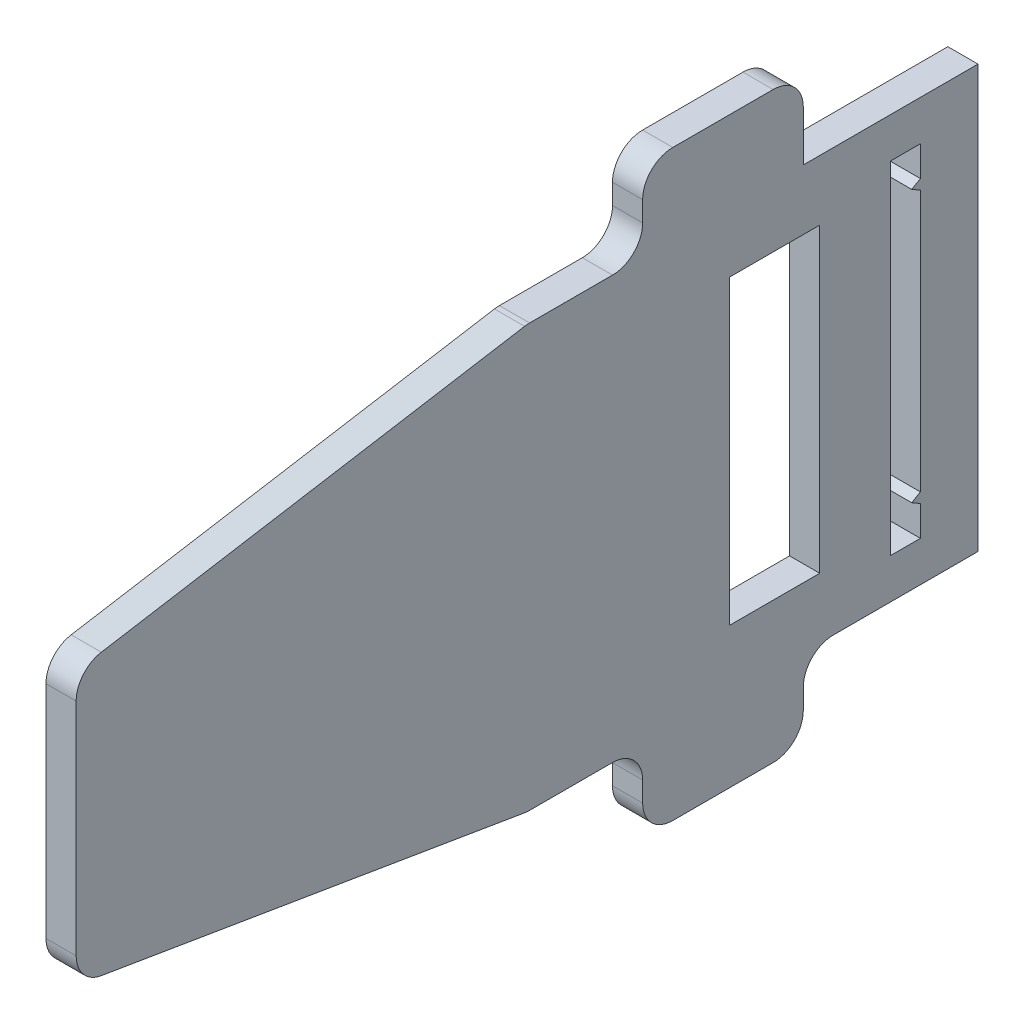
from build123d import *

# Parameters (mm, degrees)
SKETCH_1_W           = 90
SKETCH_1_H           = 58
EXTRUDE_1_DEPTH      = 3
SKETCH_3_OUTSIDE_W   = 113.422
SKETCH_3_OUTSIDE_H   = 81.422
SKETCH_3_OUTSIDE_W_2 = 3
SKETCH_3_OUTSIDE_H_2 = 34
CUT_EXTRUDE_1_DEPTH  = 3
SKETCH_4_W           = 9
SKETCH_4_H           = 30
CUT_EXTRUDE_2_DEPTH  = 4
FILLET_1_R           = 3
EXTRUDE_2_DEPTH      = 3


with BuildPart() as part:
    # 스케치1 → 보스-돌출1 (new body)
    with BuildSketch(Plane(origin=(0, 0, 0), x_dir=(0, 0, -1), z_dir=(1, 0, 0))):
        with Locations((45, 29)):
            Rectangle(SKETCH_1_W, SKETCH_1_H)
    extrude(amount=EXTRUDE_1_DEPTH)

    # 스케치3 outside → 컷-돌출1 (cut)
    with BuildSketch(Plane(origin=(3, 0, 0), x_dir=(0, 0, -1), z_dir=(1, 0, 0))):
        with Locations((45, 29)):
            Rectangle(SKETCH_3_OUTSIDE_W, SKETCH_3_OUTSIDE_H)
        Polygon((44.864431473, 50), (56.362384973, 50), (56.362384973, 58), (72.348389068, 58), (72.348389068, 50), (89.728862946, 50), (89.728862946, 8), (72.348389068, 8), (72.348389068, 0), (56.362384973, 0), (56.362384973, 8), (44.864431473, 8), (0, 15.482252367), (0, 42.517747633), align=None, mode=Mode.SUBTRACT)
        with Locations((82.5, 29)):
            Rectangle(SKETCH_3_OUTSIDE_W_2, SKETCH_3_OUTSIDE_H_2)
    extrude(amount=-CUT_EXTRUDE_1_DEPTH, mode=Mode.SUBTRACT)

    # 스케치4 → 컷-돌출2 (cut, through all)
    with BuildSketch(Plane(origin=(3, 0, 0), x_dir=(0, 0, -1), z_dir=(1, 0, 0))):
        with Locations((69.481068703, 29)):
            Rectangle(SKETCH_4_W, SKETCH_4_H)
    extrude(amount=-CUT_EXTRUDE_2_DEPTH, mode=Mode.SUBTRACT)

    # 필렛1
    fillet_1_edges = [part.edges().sort_by_distance(p)[0] for p in [
        (1.5, 8, -72.348389068),
        (1.5, 0, -72.348389068),
        (1.5, 0, -56.362384973),
        (1.5, 8, -56.362384973),
        (1.5, 8, -44.864431473),
        (1.5, 15.482252367, 0),
        (1.5, 42.517747633, 0),
        (1.5, 50, -44.864431473),
        (1.5, 50, -56.362384973),
        (1.5, 58, -56.362384973),
        (1.5, 58, -72.348389068),
    ]]
    fillet(fillet_1_edges, radius=FILLET_1_R)

    # 스케치5 → 보스-돌출2 (add)
    with BuildSketch(Plane(origin=(3, 0, 0), x_dir=(0, 0, -1), z_dir=(1, 0, 0))):
        Polygon((84, 43), (83.133974596, 42.5), (84, 42), align=None)
        Polygon((83.133974596, 15.5), (84, 16), (84, 15), align=None)
    extrude(amount=-EXTRUDE_2_DEPTH)


solid = part.part
